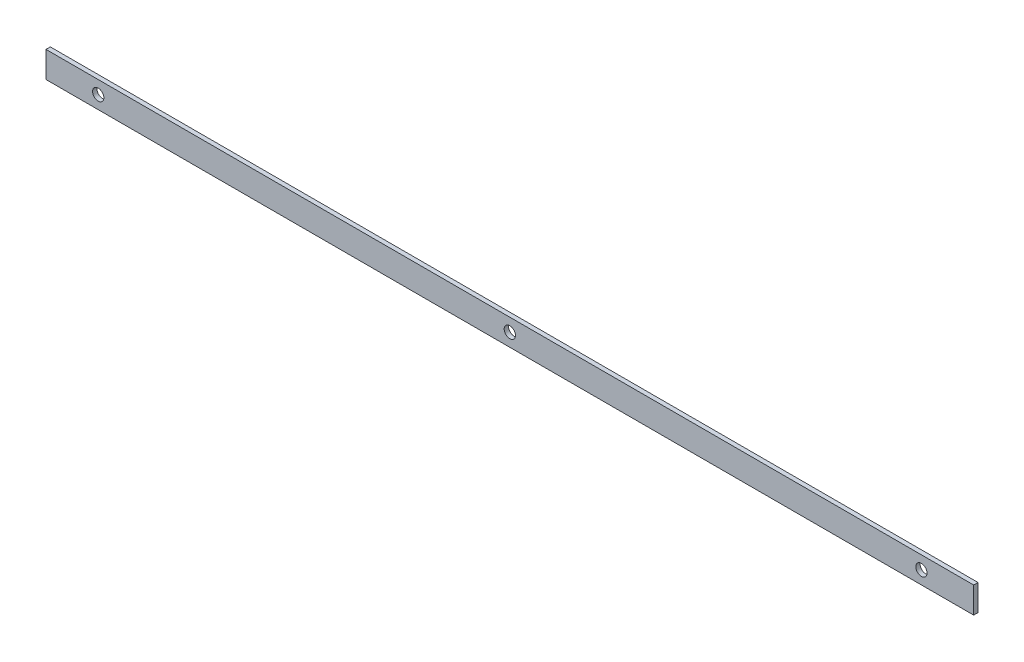
from build123d import *

# Parameters (mm, degrees)
PLAT_W                          = 30
PLAT_H                          = 5
EL_MENT_M_CANO_SOUD_1_DEPTH     = 1066
DIAM_TRE_DU_PER_AGE_13_0_13_1_D = 13
R_P_TITION_LIN_AIRE2_COUNT      = 3
R_P_TITION_LIN_AIRE2_PITCH      = 473


with BuildPart() as part:
    # plat → Elément mécano-soudé1 (new body)
    with BuildSketch(Plane.YZ.offset(-533)):
        Rectangle(PLAT_W, PLAT_H)
    extrude(amount=EL_MENT_M_CANO_SOUD_1_DEPTH)

    # Diamètre du perçage Ø13.0 (13)1 (through all)
    with Locations(Plane(origin=(0, 0, -2.5), x_dir=(-1, 0, 0), z_dir=(0, 0, -1))):
        with Locations((473, 0)):
            diam_tre_du_per_age_13_0_13_1 = Hole(DIAM_TRE_DU_PER_AGE_13_0_13_1_D / 2)

    # Répétition linéaire2: Diamètre du perçage Ø13.0 (13)1 ×3
    with Locations(*[(i * R_P_TITION_LIN_AIRE2_PITCH, 0, 0) for i in range(1, R_P_TITION_LIN_AIRE2_COUNT)]):
        add(diam_tre_du_per_age_13_0_13_1, mode=Mode.SUBTRACT)


solid = part.part
